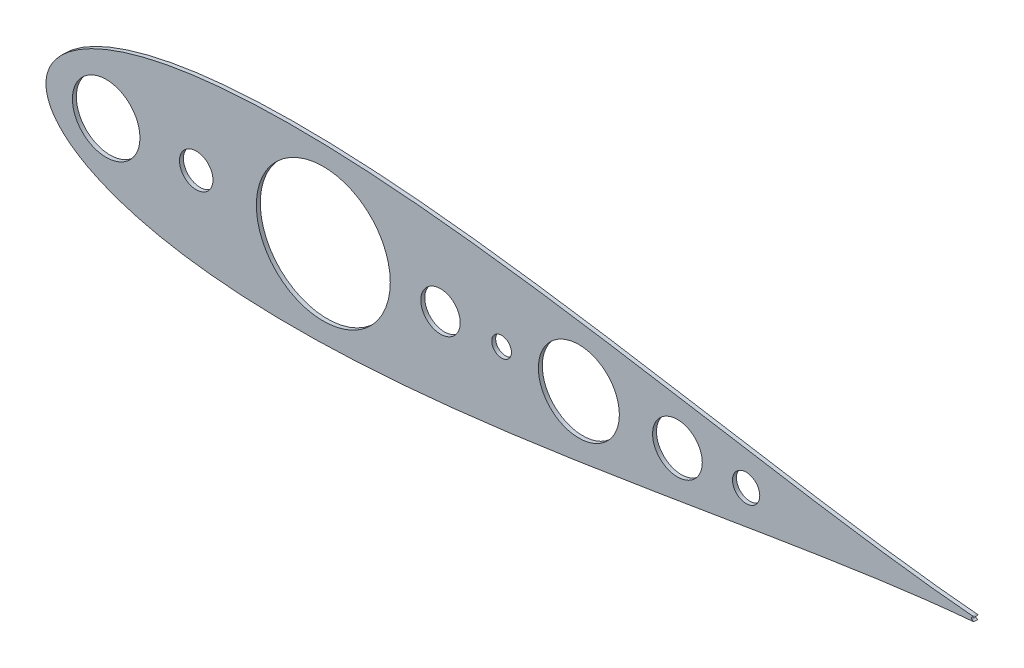
from build123d import *

# Parameters (mm, degrees)
SKETCH2_R           = 10.795
SKETCH2_R_2         = 12.7
SKETCH2_R_3         = 6.35
SKETCH2_R_4         = 16.028770825
SKETCH2_R_5         = 8.77991455
SKETCH2_R_6         = 21.7634135
SKETCH2_R_7         = 26.10316595
SKETCH2_R_8         = 43.16695288
BOSS_EXTRUDE1_DEPTH = 2.54


with BuildPart() as part:
    # Sketch2 → Boss-Extrude1 (new body)
    with BuildSketch(Plane.XY):
        with BuildLine():
            ThreePointArc((500.684889833, -1.471296373), (501.068972253, -1.386797343), (501.417120594, -1.203898123))
            ThreePointArc((501.417120594, -1.203898123), (499.856367465, 0.000160346), (501.417667224, 1.203509915))
            ThreePointArc((501.417667224, 1.203509915), (501.069287129, 1.386682318), (500.684889833, 1.471296376))
            add(Edge.make_bspline(
                [(500.684889833, 1.471296376), (500.203654887, 1.51131569), (496.576967436, 1.816798163), (489.434650237, 2.476948512), (478.832935497, 3.579805911), (467.078539314, 4.933118958), (454.215647937, 6.545000467), (440.304272306, 8.417091621), (425.40457178, 10.545195255), (409.581067447, 12.918318802), (392.900953599, 15.519580304), (375.434110154, 18.32575385), (357.252720565, 21.307855523), (338.43106199, 24.43150554), (319.045264622, 27.657276915), (299.173184121, 30.941401436), (278.894273561, 34.236295111), (258.289516453, 37.49133818), (237.44138285, 40.653557359), (216.433826057, 43.668566139), (195.3522728, 46.481254826), (174.283643962, 49.036772818), (153.316369016, 51.281316945), (132.540399542, 53.163081565), (112.047200631, 54.63301428), (91.929749114, 55.645733185), (72.28251333, 56.160380716), (53.201420992, 56.141274035), (34.783891457, 55.55810312), (17.12883725, 54.38803504), (0.336951484, 52.614102661), (-15.489132671, 50.228309739), (-30.243882646, 47.229819367), (-43.818149959, 43.628665055), (-56.097177476, 39.445952292), (-66.958469931, 34.71894975), (-76.270130144, 29.510253469), (-83.893046126, 23.925563262), (-89.698856668, 18.147283101), (-93.629483204, 12.480929615), (-95.821310101, 7.368752178), (-96.706411232, 3.267830856), (-96.908000989, 4e-09), (-96.706411232, -3.267830848), (-95.821310101, -7.368752171), (-93.629483204, -12.480929607), (-89.698856668, -18.147283094), (-83.893046126, -23.925563255), (-76.270130144, -29.510253461), (-66.958469931, -34.718949743), (-56.097177476, -39.445952284), (-43.818149959, -43.628665047), (-30.243882646, -47.229819359), (-15.489132671, -50.228309731), (0.336951484, -52.614102653), (17.12883725, -54.388035033), (34.783891457, -55.558103113), (53.201420992, -56.141274028), (72.28251333, -56.160380708), (91.929749114, -55.645733177), (112.047200631, -54.633014273), (132.540399542, -53.163081557), (153.316369016, -51.281316937), (174.283643962, -49.036772811), (195.3522728, -46.481254819), (216.433826057, -43.668566131), (237.44138285, -40.653557351), (258.289516453, -37.491338173), (278.894273561, -34.236295103), (299.173184121, -30.941401428), (319.045264622, -27.657276908), (338.43106199, -24.431505532), (357.252720565, -21.307855515), (375.434110154, -18.325753843), (392.900953599, -15.519580296), (409.581067447, -12.918318795), (425.40457178, -10.545195247), (440.304272306, -8.417091613), (454.215647937, -6.54500046), (467.078539314, -4.933118951), (478.832935497, -3.579805904), (489.434650237, -2.476948505), (496.576967436, -1.816798155), (500.203654887, -1.511315683), (500.684889833, -1.471296373)],
                knots=[0.020157042, 0.020157042, 0.020157042, 0.020157042, 0.021270888, 0.028552555, 0.036780684, 0.045920102, 0.055931764, 0.066772884, 0.07839713, 0.090754827, 0.103793165, 0.117456432, 0.131686226, 0.146421738, 0.161599998, 0.177156133, 0.193023668, 0.209134786, 0.225420633, 0.241811602, 0.258237647, 0.274628557, 0.290914287, 0.307025229, 0.322892517, 0.338448342, 0.353626207, 0.368361232, 0.382590428, 0.396252961, 0.409290412, 0.42164701, 0.433269881, 0.444109249, 0.45411864, 0.463255055, 0.471479114, 0.478755289, 0.485052318, 0.490344026, 0.494609833, 0.497833231, 0.5, 0.502166769, 0.505390167, 0.509655974, 0.514947682, 0.521244711, 0.528520886, 0.536744945, 0.54588136, 0.555890751, 0.566730119, 0.57835299, 0.590709588, 0.603747039, 0.617409572, 0.631638768, 0.646373793, 0.661551658, 0.677107483, 0.692974771, 0.709085713, 0.725371443, 0.741762353, 0.758188398, 0.774579367, 0.790865214, 0.806976332, 0.822843867, 0.838400002, 0.853578262, 0.868313774, 0.882543568, 0.896206835, 0.909245173, 0.92160287, 0.933227116, 0.944068236, 0.954079898, 0.963219316, 0.971447445, 0.978729112, 0.979842958, 0.979842958, 0.979842958, 0.979842958], degree=3))
        make_face()
        Circle(SKETCH2_R, mode=Mode.SUBTRACT)
        with Locations((157.48, 0)):
            Circle(SKETCH2_R_2, mode=Mode.SUBTRACT)
        with Locations((196.85, 0)):
            Circle(SKETCH2_R_3, mode=Mode.SUBTRACT)
        with Locations((310.19216791, 0)):
            Circle(SKETCH2_R_4, mode=Mode.SUBTRACT)
        with Locations((354.486263574, 0)):
            Circle(SKETCH2_R_5, mode=Mode.SUBTRACT)
        with Locations((-58.058197117, 0)):
            Circle(SKETCH2_R_6, mode=Mode.SUBTRACT)
        with Locations((246.656608479, 0)):
            Circle(SKETCH2_R_7, mode=Mode.SUBTRACT)
        with Locations((81.919361729, 0)):
            Circle(SKETCH2_R_8, mode=Mode.SUBTRACT)
    extrude(amount=BOSS_EXTRUDE1_DEPTH)


solid = part.part
